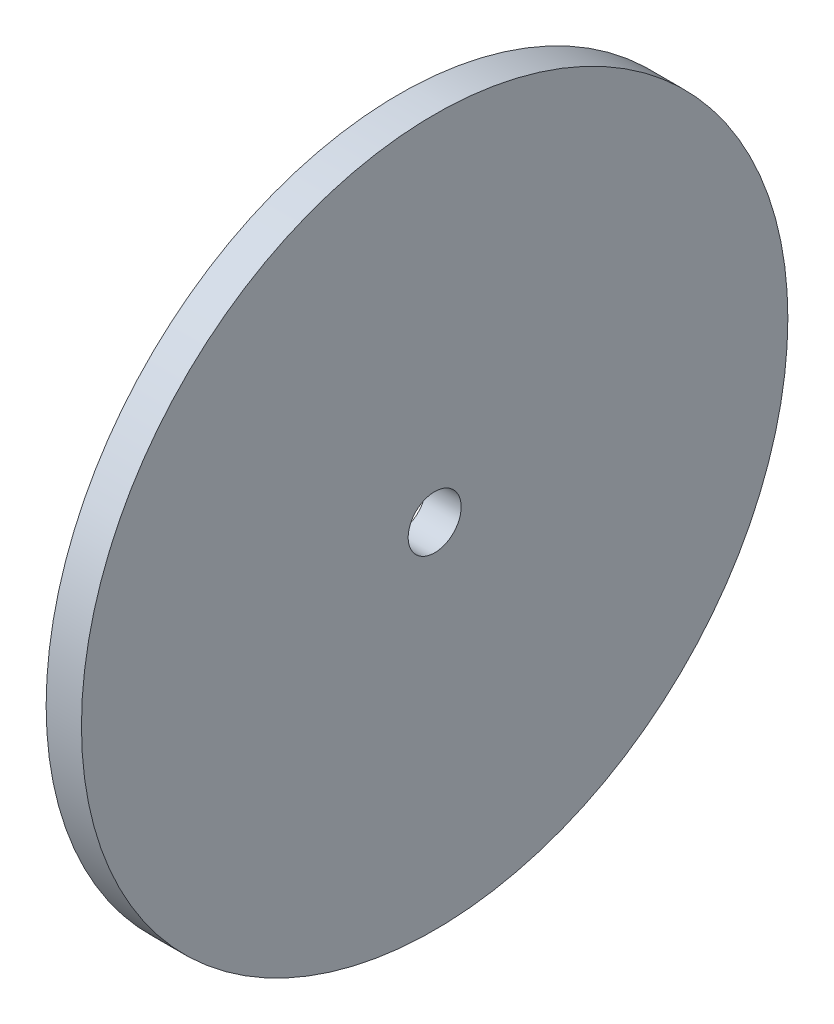
from build123d import *

# Parameters (mm, degrees)
SKETCH1_R           = 20
BOSS_EXTRUDE1_DEPTH = 2
SKETCH2_R           = 1.5
CUT_EXTRUDE1_DEPTH  = 3


with BuildPart() as part:
    # Sketch1 → Boss-Extrude1 (new body)
    with BuildSketch(Plane(origin=(0, 0, 0), x_dir=(0, 0, -1), z_dir=(1, 0, 0))):
        Circle(SKETCH1_R)
    extrude(amount=BOSS_EXTRUDE1_DEPTH)

    # Sketch2 → Cut-Extrude1 (cut, through all)
    with BuildSketch(Plane(origin=(2, 0, 0), x_dir=(0, 0, -1), z_dir=(1, 0, 0))):
        Circle(SKETCH2_R)
    extrude(amount=-CUT_EXTRUDE1_DEPTH, mode=Mode.SUBTRACT)


solid = part.part
